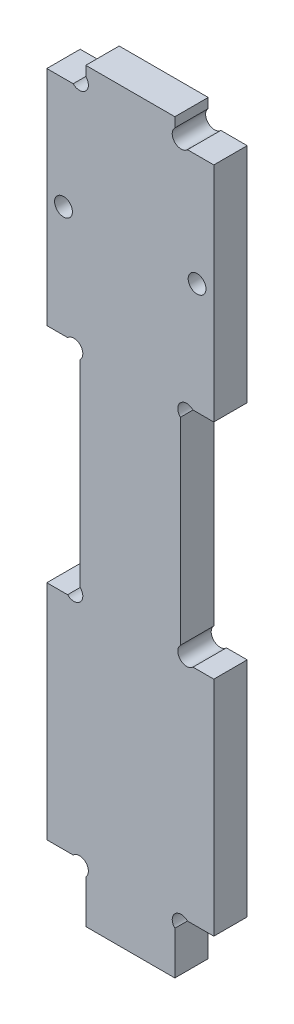
from build123d import *

# Parameters (mm, degrees)
ESQUISSE1_R      = 1.6
EXTRUSION1_DEPTH = 6


with BuildPart() as part:
    # Esquisse1 → Extrusion1 (new body)
    with BuildSketch(Plane.XY):
        with BuildLine():
            Line((25.2627417, 10), (30, 10))
            Line((30, 10), (30, 50))
            Line((30, 50), (26.2627417, 50))
            ThreePointArc((26.2627417, 50), (24, 50), (24, 52.2627417))
            Line((24, 52.2627417), (24, 87.7372583))
            ThreePointArc((24, 87.7372583), (24, 90), (26.2627417, 90))
            Line((26.2627417, 90), (30, 90))
            Line((30, 90), (30, 130))
            Line((30, 130), (25.2627417, 130))
            ThreePointArc((25.2627417, 130), (23, 130), (23, 132.2627417))
            Line((23, 132.2627417), (23, 134))
            Line((23, 134), (7, 134))
            Line((7, 134), (7, 132.2627417))
            ThreePointArc((7, 132.2627417), (7, 130), (4.7372583, 130))
            Line((4.7372583, 130), (0, 130))
            Line((0, 130), (0, 90))
            Line((0, 90), (3.7372583, 90))
            ThreePointArc((3.7372583, 90), (6, 90), (6, 87.7372583))
            Line((6, 87.7372583), (6, 52.2627417))
            ThreePointArc((6, 52.2627417), (6, 50), (3.7372583, 50))
            Line((3.7372583, 50), (0, 50))
            Line((0, 50), (0, 10))
            Line((0, 10), (4.7372583, 10))
            ThreePointArc((4.7372583, 10), (7, 10), (7, 7.7372583))
            Line((7, 7.7372583), (7, 0))
            Line((7, 0), (23, 0))
            Line((23, 0), (23, 7.7372583))
            ThreePointArc((23, 7.7372583), (23, 10), (25.2627417, 10))
        make_face()
        with Locations(Location((27, 110, 0), (0, 0, 180))):  # turned: the seam where the file's is
            Circle(ESQUISSE1_R, mode=Mode.SUBTRACT)
        with Locations((3, 110)):
            Circle(ESQUISSE1_R, mode=Mode.SUBTRACT)
    extrude(amount=EXTRUSION1_DEPTH)


solid = part.part
